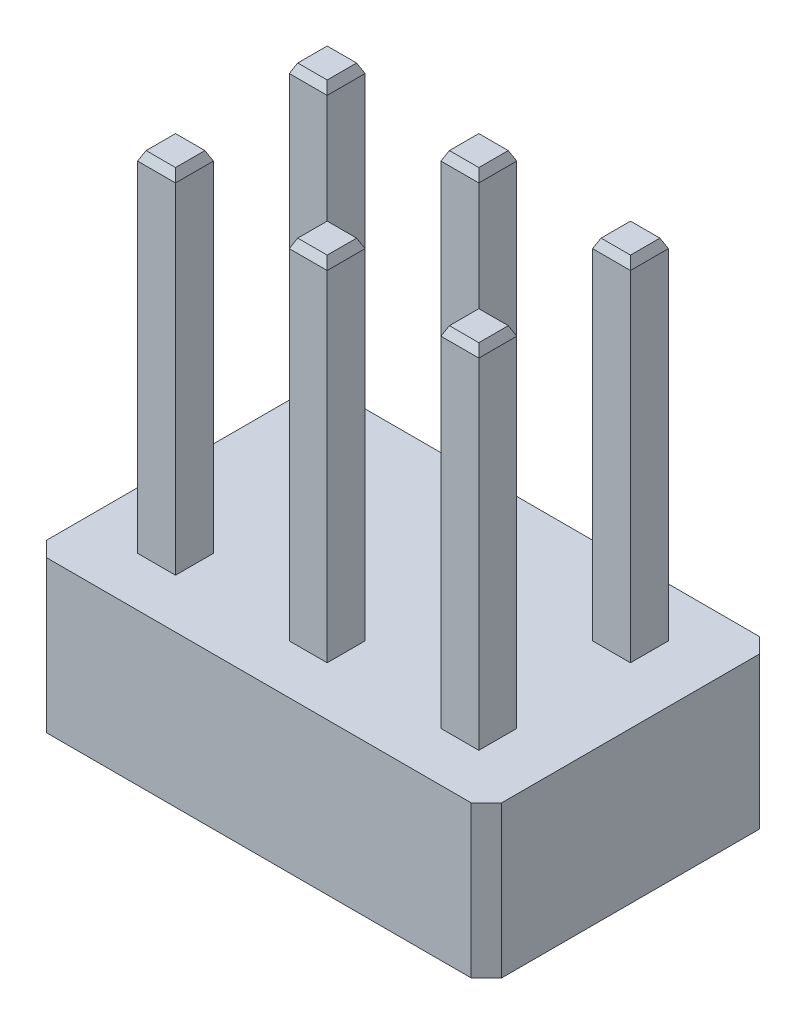
from build123d import *
from OCP.BRepFilletAPI import BRepFilletAPI_MakeChamfer

# Parameters (mm, degrees)
SKETCH1_W                   = 7.62
SKETCH1_H                   = 4.826
BOSS_EXTRUDE1_DEPTH         = 2.54
SKETCH2_W                   = 0.635
SKETCH2_H                   = 0.635
BOSS_EXTRUDE2_DEPTH         = 5.842
CHAMFER2_SIZE               = 0.1524
CHAMFER2_SIZE2              = 0.071065287
CHAMFER1_SIZE               = 0.254
LPATTERN2_COUNT             = 3
LPATTERN2_PITCH             = 2.54
LPATTERN2_COUNT_DIR2        = 2
LPATTERN2_PITCH_DIR2        = 2.54
CHAMFER2_OF_LPATTERN2_SIZE  = 0.1524
CHAMFER2_OF_LPATTERN2_SIZE2 = 0.071065287


with BuildPart() as part:
    # Sketch1 → Boss-Extrude1 (new body)
    with BuildSketch(Plane(origin=(0, 0, 0), x_dir=(1, 0, 0), z_dir=(0, 1, 0))):
        with Locations((3.81, 2.413)):
            Rectangle(SKETCH1_W, SKETCH1_H)
    extrude(amount=BOSS_EXTRUDE1_DEPTH)

    # Sketch2 → Boss-Extrude2 (add)
    with BuildSketch(Plane(origin=(0, 2.54, 0), x_dir=(1, 0, 0), z_dir=(0, 1, 0))):
        with Locations((1.27, 1.143)):
            Rectangle(SKETCH2_W, SKETCH2_H)
    boss_extrude2 = extrude(amount=BOSS_EXTRUDE2_DEPTH)

    # Chamfer2: one chamfer whose edges measure the first distance from different faces: ONE call of the kernel's chamfer builder (chamfer() names one face for all edges)
    chamfer2_edges_1 = [part.edges().sort_by_distance(p)[0] for p in [
        (1.5875, 8.382, -1.143),
    ]]
    chamfer2_side_1 = [part.faces().sort_by_distance(p)[0] for p in [
        (1.5875, 5.461, -1.143),
    ]]
    chamfer2_edges_2 = [part.edges().sort_by_distance(p)[0] for p in [
        (1.27, 8.382, -1.4605),
    ]]
    chamfer2_side_2 = [part.faces().sort_by_distance(p)[0] for p in [
        (1.27, 5.461, -1.4605),
    ]]
    chamfer2_edges_3 = [part.edges().sort_by_distance(p)[0] for p in [
        (0.9525, 8.382, -1.143),
    ]]
    chamfer2_side_3 = [part.faces().sort_by_distance(p)[0] for p in [
        (0.9525, 5.461, -1.143),
    ]]
    chamfer2_edges_4 = [part.edges().sort_by_distance(p)[0] for p in [
        (1.27, 8.382, -0.8255),
    ]]
    chamfer2_side_4 = [part.faces().sort_by_distance(p)[0] for p in [
        (1.27, 5.461, -0.8255),
    ]]
    chamfer2 = BRepFilletAPI_MakeChamfer(part.part.solid().wrapped)
    for e in chamfer2_edges_1:
        chamfer2.Add(CHAMFER2_SIZE, CHAMFER2_SIZE2, e.wrapped, chamfer2_side_1[0].wrapped)  # the first distance lies on this face
    for e in chamfer2_edges_2:
        chamfer2.Add(CHAMFER2_SIZE, CHAMFER2_SIZE2, e.wrapped, chamfer2_side_2[0].wrapped)  # the first distance lies on this face
    for e in chamfer2_edges_3:
        chamfer2.Add(CHAMFER2_SIZE, CHAMFER2_SIZE2, e.wrapped, chamfer2_side_3[0].wrapped)  # the first distance lies on this face
    for e in chamfer2_edges_4:
        chamfer2.Add(CHAMFER2_SIZE, CHAMFER2_SIZE2, e.wrapped, chamfer2_side_4[0].wrapped)  # the first distance lies on this face
    add(Compound.cast(chamfer2.Shape()), mode=Mode.REPLACE)

    # Chamfer1
    chamfer1_edges = [part.edges().sort_by_distance(p)[0] for p in [
        (0, 1.27, -4.826),
        (7.62, 1.27, -4.826),
        (7.62, 1.27, 0),
        (0, 1.27, 0),
    ]]
    chamfer(chamfer1_edges, length=CHAMFER1_SIZE)

    # LPattern2: Boss-Extrude2 3 × 2
    with Locations(*[(i * LPATTERN2_PITCH, 0, -j * LPATTERN2_PITCH_DIR2) for i in range(LPATTERN2_COUNT) for j in range(LPATTERN2_COUNT_DIR2) if (i, j) != (0, 0)]):
        add(boss_extrude2)

    # Chamfer2 of LPattern2: one chamfer whose edges measure the first distance from different faces: ONE call of the kernel's chamfer builder (chamfer() names one face for all edges)
    chamfer2_of_lpattern2_edges_1 = [part.edges().sort_by_distance(p)[0] for p in [
        (1.5875, 8.382, -3.683),
    ]]
    chamfer2_of_lpattern2_side_1 = [part.faces().sort_by_distance(p)[0] for p in [
        (1.5875, 5.461, -3.683),
    ]]
    chamfer2_of_lpattern2_edges_2 = [part.edges().sort_by_distance(p)[0] for p in [
        (1.27, 8.382, -4.0005),
    ]]
    chamfer2_of_lpattern2_side_2 = [part.faces().sort_by_distance(p)[0] for p in [
        (1.27, 5.461, -4.0005),
    ]]
    chamfer2_of_lpattern2_edges_3 = [part.edges().sort_by_distance(p)[0] for p in [
        (0.9525, 8.382, -3.683),
    ]]
    chamfer2_of_lpattern2_side_3 = [part.faces().sort_by_distance(p)[0] for p in [
        (0.9525, 5.461, -3.683),
    ]]
    chamfer2_of_lpattern2_edges_4 = [part.edges().sort_by_distance(p)[0] for p in [
        (1.27, 8.382, -3.3655),
    ]]
    chamfer2_of_lpattern2_side_4 = [part.faces().sort_by_distance(p)[0] for p in [
        (1.27, 5.461, -3.3655),
    ]]
    chamfer2_of_lpattern2_edges_5 = [part.edges().sort_by_distance(p)[0] for p in [
        (4.1275, 8.382, -1.143),
    ]]
    chamfer2_of_lpattern2_side_5 = [part.faces().sort_by_distance(p)[0] for p in [
        (4.1275, 5.461, -1.143),
    ]]
    chamfer2_of_lpattern2_edges_6 = [part.edges().sort_by_distance(p)[0] for p in [
        (3.81, 8.382, -1.4605),
    ]]
    chamfer2_of_lpattern2_side_6 = [part.faces().sort_by_distance(p)[0] for p in [
        (3.81, 5.461, -1.4605),
    ]]
    chamfer2_of_lpattern2_edges_7 = [part.edges().sort_by_distance(p)[0] for p in [
        (3.4925, 8.382, -1.143),
    ]]
    chamfer2_of_lpattern2_side_7 = [part.faces().sort_by_distance(p)[0] for p in [
        (3.4925, 5.461, -1.143),
    ]]
    chamfer2_of_lpattern2_edges_8 = [part.edges().sort_by_distance(p)[0] for p in [
        (3.81, 8.382, -0.8255),
    ]]
    chamfer2_of_lpattern2_side_8 = [part.faces().sort_by_distance(p)[0] for p in [
        (3.81, 5.461, -0.8255),
    ]]
    chamfer2_of_lpattern2_edges_9 = [part.edges().sort_by_distance(p)[0] for p in [
        (4.1275, 8.382, -3.683),
    ]]
    chamfer2_of_lpattern2_side_9 = [part.faces().sort_by_distance(p)[0] for p in [
        (4.1275, 5.461, -3.683),
    ]]
    chamfer2_of_lpattern2_edges_10 = [part.edges().sort_by_distance(p)[0] for p in [
        (3.81, 8.382, -4.0005),
    ]]
    chamfer2_of_lpattern2_side_10 = [part.faces().sort_by_distance(p)[0] for p in [
        (3.81, 5.461, -4.0005),
    ]]
    chamfer2_of_lpattern2_edges_11 = [part.edges().sort_by_distance(p)[0] for p in [
        (3.4925, 8.382, -3.683),
    ]]
    chamfer2_of_lpattern2_side_11 = [part.faces().sort_by_distance(p)[0] for p in [
        (3.4925, 5.461, -3.683),
    ]]
    chamfer2_of_lpattern2_edges_12 = [part.edges().sort_by_distance(p)[0] for p in [
        (3.81, 8.382, -3.3655),
    ]]
    chamfer2_of_lpattern2_side_12 = [part.faces().sort_by_distance(p)[0] for p in [
        (3.81, 5.461, -3.3655),
    ]]
    chamfer2_of_lpattern2_edges_13 = [part.edges().sort_by_distance(p)[0] for p in [
        (6.6675, 8.382, -1.143),
    ]]
    chamfer2_of_lpattern2_side_13 = [part.faces().sort_by_distance(p)[0] for p in [
        (6.6675, 5.461, -1.143),
    ]]
    chamfer2_of_lpattern2_edges_14 = [part.edges().sort_by_distance(p)[0] for p in [
        (6.35, 8.382, -1.4605),
    ]]
    chamfer2_of_lpattern2_side_14 = [part.faces().sort_by_distance(p)[0] for p in [
        (6.35, 5.461, -1.4605),
    ]]
    chamfer2_of_lpattern2_edges_15 = [part.edges().sort_by_distance(p)[0] for p in [
        (6.0325, 8.382, -1.143),
    ]]
    chamfer2_of_lpattern2_side_15 = [part.faces().sort_by_distance(p)[0] for p in [
        (6.0325, 5.461, -1.143),
    ]]
    chamfer2_of_lpattern2_edges_16 = [part.edges().sort_by_distance(p)[0] for p in [
        (6.35, 8.382, -0.8255),
    ]]
    chamfer2_of_lpattern2_side_16 = [part.faces().sort_by_distance(p)[0] for p in [
        (6.35, 5.461, -0.8255),
    ]]
    chamfer2_of_lpattern2_edges_17 = [part.edges().sort_by_distance(p)[0] for p in [
        (6.6675, 8.382, -3.683),
    ]]
    chamfer2_of_lpattern2_side_17 = [part.faces().sort_by_distance(p)[0] for p in [
        (6.6675, 5.461, -3.683),
    ]]
    chamfer2_of_lpattern2_edges_18 = [part.edges().sort_by_distance(p)[0] for p in [
        (6.35, 8.382, -4.0005),
    ]]
    chamfer2_of_lpattern2_side_18 = [part.faces().sort_by_distance(p)[0] for p in [
        (6.35, 5.461, -4.0005),
    ]]
    chamfer2_of_lpattern2_edges_19 = [part.edges().sort_by_distance(p)[0] for p in [
        (6.0325, 8.382, -3.683),
    ]]
    chamfer2_of_lpattern2_side_19 = [part.faces().sort_by_distance(p)[0] for p in [
        (6.0325, 5.461, -3.683),
    ]]
    chamfer2_of_lpattern2_edges_20 = [part.edges().sort_by_distance(p)[0] for p in [
        (6.35, 8.382, -3.3655),
    ]]
    chamfer2_of_lpattern2_side_20 = [part.faces().sort_by_distance(p)[0] for p in [
        (6.35, 5.461, -3.3655),
    ]]
    chamfer2_of_lpattern2 = BRepFilletAPI_MakeChamfer(part.part.solid().wrapped)
    for e in chamfer2_of_lpattern2_edges_1:
        chamfer2_of_lpattern2.Add(CHAMFER2_OF_LPATTERN2_SIZE, CHAMFER2_OF_LPATTERN2_SIZE2, e.wrapped, chamfer2_of_lpattern2_side_1[0].wrapped)  # the first distance lies on this face
    for e in chamfer2_of_lpattern2_edges_2:
        chamfer2_of_lpattern2.Add(CHAMFER2_OF_LPATTERN2_SIZE, CHAMFER2_OF_LPATTERN2_SIZE2, e.wrapped, chamfer2_of_lpattern2_side_2[0].wrapped)  # the first distance lies on this face
    for e in chamfer2_of_lpattern2_edges_3:
        chamfer2_of_lpattern2.Add(CHAMFER2_OF_LPATTERN2_SIZE, CHAMFER2_OF_LPATTERN2_SIZE2, e.wrapped, chamfer2_of_lpattern2_side_3[0].wrapped)  # the first distance lies on this face
    for e in chamfer2_of_lpattern2_edges_4:
        chamfer2_of_lpattern2.Add(CHAMFER2_OF_LPATTERN2_SIZE, CHAMFER2_OF_LPATTERN2_SIZE2, e.wrapped, chamfer2_of_lpattern2_side_4[0].wrapped)  # the first distance lies on this face
    for e in chamfer2_of_lpattern2_edges_5:
        chamfer2_of_lpattern2.Add(CHAMFER2_OF_LPATTERN2_SIZE, CHAMFER2_OF_LPATTERN2_SIZE2, e.wrapped, chamfer2_of_lpattern2_side_5[0].wrapped)  # the first distance lies on this face
    for e in chamfer2_of_lpattern2_edges_6:
        chamfer2_of_lpattern2.Add(CHAMFER2_OF_LPATTERN2_SIZE, CHAMFER2_OF_LPATTERN2_SIZE2, e.wrapped, chamfer2_of_lpattern2_side_6[0].wrapped)  # the first distance lies on this face
    for e in chamfer2_of_lpattern2_edges_7:
        chamfer2_of_lpattern2.Add(CHAMFER2_OF_LPATTERN2_SIZE, CHAMFER2_OF_LPATTERN2_SIZE2, e.wrapped, chamfer2_of_lpattern2_side_7[0].wrapped)  # the first distance lies on this face
    for e in chamfer2_of_lpattern2_edges_8:
        chamfer2_of_lpattern2.Add(CHAMFER2_OF_LPATTERN2_SIZE, CHAMFER2_OF_LPATTERN2_SIZE2, e.wrapped, chamfer2_of_lpattern2_side_8[0].wrapped)  # the first distance lies on this face
    for e in chamfer2_of_lpattern2_edges_9:
        chamfer2_of_lpattern2.Add(CHAMFER2_OF_LPATTERN2_SIZE, CHAMFER2_OF_LPATTERN2_SIZE2, e.wrapped, chamfer2_of_lpattern2_side_9[0].wrapped)  # the first distance lies on this face
    for e in chamfer2_of_lpattern2_edges_10:
        chamfer2_of_lpattern2.Add(CHAMFER2_OF_LPATTERN2_SIZE, CHAMFER2_OF_LPATTERN2_SIZE2, e.wrapped, chamfer2_of_lpattern2_side_10[0].wrapped)  # the first distance lies on this face
    for e in chamfer2_of_lpattern2_edges_11:
        chamfer2_of_lpattern2.Add(CHAMFER2_OF_LPATTERN2_SIZE, CHAMFER2_OF_LPATTERN2_SIZE2, e.wrapped, chamfer2_of_lpattern2_side_11[0].wrapped)  # the first distance lies on this face
    for e in chamfer2_of_lpattern2_edges_12:
        chamfer2_of_lpattern2.Add(CHAMFER2_OF_LPATTERN2_SIZE, CHAMFER2_OF_LPATTERN2_SIZE2, e.wrapped, chamfer2_of_lpattern2_side_12[0].wrapped)  # the first distance lies on this face
    for e in chamfer2_of_lpattern2_edges_13:
        chamfer2_of_lpattern2.Add(CHAMFER2_OF_LPATTERN2_SIZE, CHAMFER2_OF_LPATTERN2_SIZE2, e.wrapped, chamfer2_of_lpattern2_side_13[0].wrapped)  # the first distance lies on this face
    for e in chamfer2_of_lpattern2_edges_14:
        chamfer2_of_lpattern2.Add(CHAMFER2_OF_LPATTERN2_SIZE, CHAMFER2_OF_LPATTERN2_SIZE2, e.wrapped, chamfer2_of_lpattern2_side_14[0].wrapped)  # the first distance lies on this face
    for e in chamfer2_of_lpattern2_edges_15:
        chamfer2_of_lpattern2.Add(CHAMFER2_OF_LPATTERN2_SIZE, CHAMFER2_OF_LPATTERN2_SIZE2, e.wrapped, chamfer2_of_lpattern2_side_15[0].wrapped)  # the first distance lies on this face
    for e in chamfer2_of_lpattern2_edges_16:
        chamfer2_of_lpattern2.Add(CHAMFER2_OF_LPATTERN2_SIZE, CHAMFER2_OF_LPATTERN2_SIZE2, e.wrapped, chamfer2_of_lpattern2_side_16[0].wrapped)  # the first distance lies on this face
    for e in chamfer2_of_lpattern2_edges_17:
        chamfer2_of_lpattern2.Add(CHAMFER2_OF_LPATTERN2_SIZE, CHAMFER2_OF_LPATTERN2_SIZE2, e.wrapped, chamfer2_of_lpattern2_side_17[0].wrapped)  # the first distance lies on this face
    for e in chamfer2_of_lpattern2_edges_18:
        chamfer2_of_lpattern2.Add(CHAMFER2_OF_LPATTERN2_SIZE, CHAMFER2_OF_LPATTERN2_SIZE2, e.wrapped, chamfer2_of_lpattern2_side_18[0].wrapped)  # the first distance lies on this face
    for e in chamfer2_of_lpattern2_edges_19:
        chamfer2_of_lpattern2.Add(CHAMFER2_OF_LPATTERN2_SIZE, CHAMFER2_OF_LPATTERN2_SIZE2, e.wrapped, chamfer2_of_lpattern2_side_19[0].wrapped)  # the first distance lies on this face
    for e in chamfer2_of_lpattern2_edges_20:
        chamfer2_of_lpattern2.Add(CHAMFER2_OF_LPATTERN2_SIZE, CHAMFER2_OF_LPATTERN2_SIZE2, e.wrapped, chamfer2_of_lpattern2_side_20[0].wrapped)  # the first distance lies on this face
    add(Compound.cast(chamfer2_of_lpattern2.Shape()), mode=Mode.REPLACE)


solid = part.part
